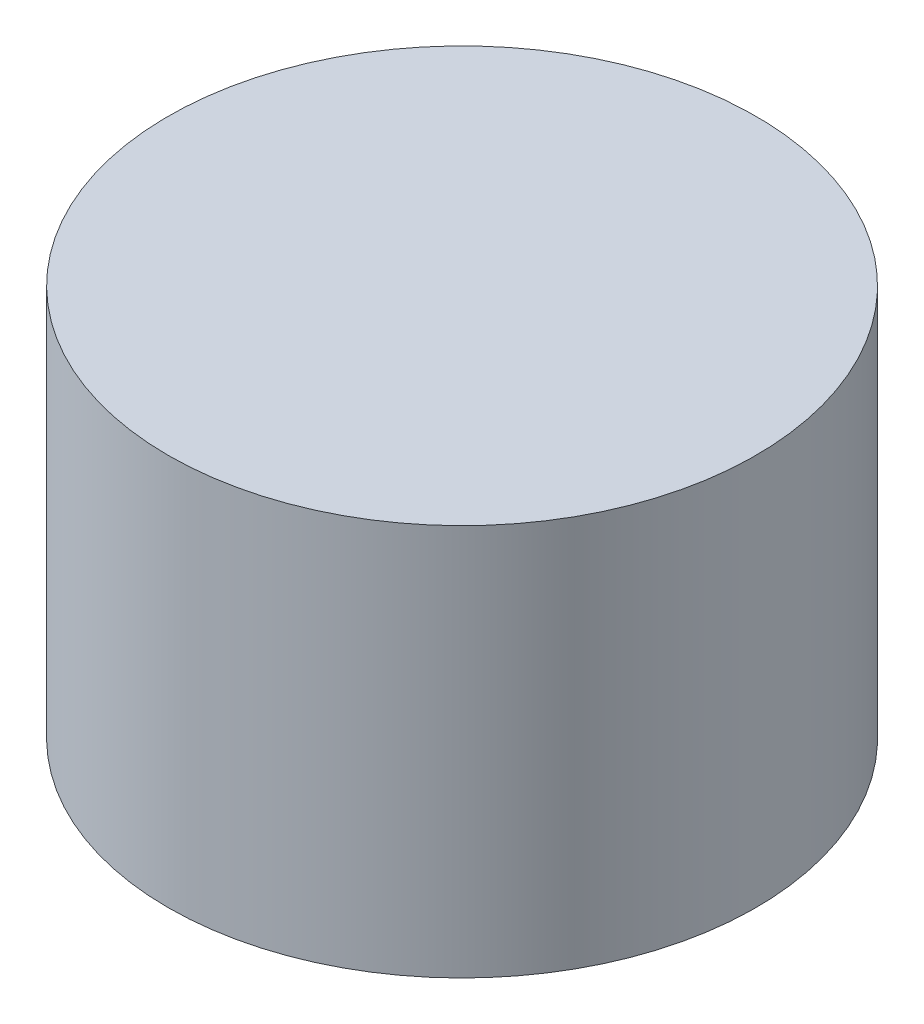
from build123d import *

# Parameters (mm, degrees)
SKETCH_1_R      = 1.5
EXTRUDE_1_DEPTH = 2


with BuildPart() as part:
    # 草图1 → 凸台-拉伸1 (new body)
    with BuildSketch(Plane(origin=(0, 0, 0), x_dir=(1, 0, 0), z_dir=(0, 1, 0))):
        Circle(SKETCH_1_R)
    extrude(amount=EXTRUDE_1_DEPTH)


solid = part.part
